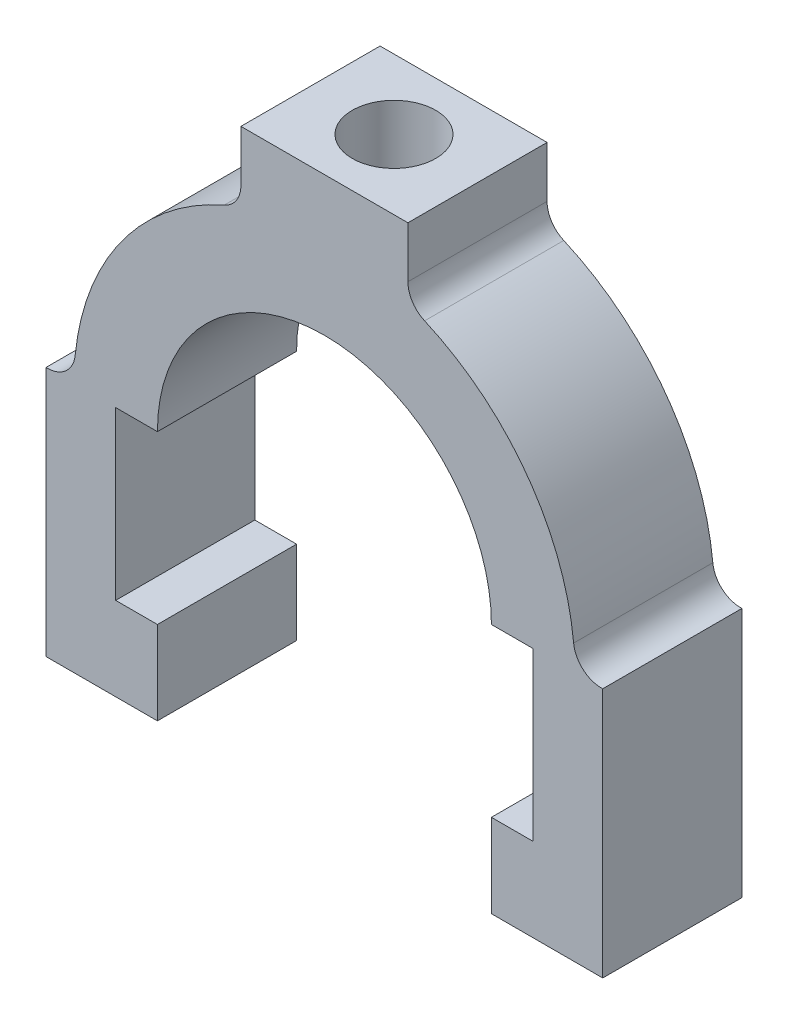
from build123d import *

# Parameters (mm, degrees)
BOSS_EXTRUDE1_DEPTH = 254
SKETCH2_R           = 152.4
CUT_EXTRUDE1_DEPTH  = 2033


with BuildPart() as part:
    # Sketch1 → Boss-Extrude1 (new body, symmetric)
    with BuildSketch(Plane.XY):
        with BuildLine():
            Line((-304.8, 2032), (304.8, 2032))
            Line((304.8, 2032), (304.8, 1845.579381215))
            ThreePointArc((304.8, 1845.579381215), (321.395341304, 1789.930769373), (365.76, 1752.461443094))
            ThreePointArc((365.76, 1752.461443094), (739.043152086, 1452.863164343), (909.828, 1005.725628473))
            ThreePointArc((909.828, 1005.725628473), (944.665425516, 938.847656099), (1016, 914.4))
            Line((1016, 914.4), (1016, 0))
            Line((1016, 0), (609.6, 0))
            Line((609.6, 0), (609.6, 304.8))
            Line((609.6, 304.8), (762, 304.8))
            Line((762, 304.8), (762, 914.4))
            Line((762, 914.4), (609.6, 914.4))
            ThreePointArc((609.6, 914.4), (0, 1524), (-609.6, 914.4))
            Line((-609.6, 914.4), (-762, 914.4))
            Line((-762, 914.4), (-762, 304.8))
            Line((-762, 304.8), (-609.6, 304.8))
            Line((-609.6, 304.8), (-609.6, 0))
            Line((-609.6, 0), (-1016, 0))
            Line((-1016, 0), (-1016, 914.4))
            ThreePointArc((-1016, 914.4), (-944.665425516, 938.847656099), (-909.828, 1005.725628473))
            ThreePointArc((-909.828, 1005.725628473), (-739.043152086, 1452.863164343), (-365.76, 1752.461443094))
            ThreePointArc((-365.76, 1752.461443094), (-321.395341304, 1789.930769373), (-304.8, 1845.579381215))
            Line((-304.8, 1845.579381215), (-304.8, 2032))
        make_face()
    extrude(amount=BOSS_EXTRUDE1_DEPTH, both=True)

    # Sketch2 → Cut-Extrude1 (cut, through all)
    with BuildSketch(Plane(origin=(0, 2032, 0), x_dir=(1, 0, 0), z_dir=(0, 1, 0))):
        Circle(SKETCH2_R)
    extrude(amount=-CUT_EXTRUDE1_DEPTH, mode=Mode.SUBTRACT)


solid = part.part
